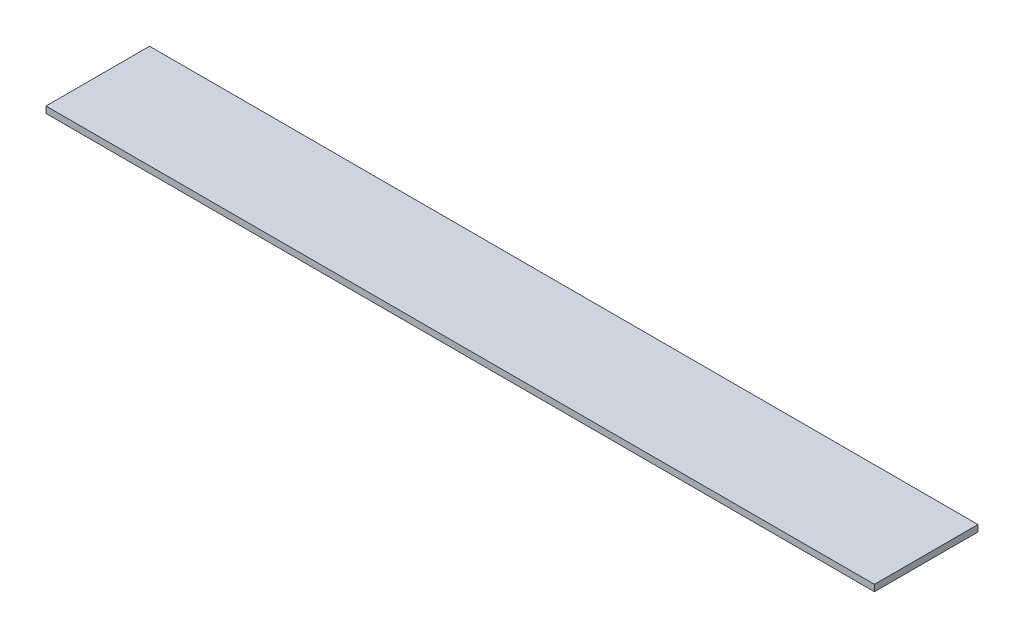
from build123d import *

# Parameters (mm, degrees)
SKETCH1_W           = 203.2
SKETCH1_H           = 25.4
BOSS_EXTRUDE1_DEPTH = 1.5875


with BuildPart() as part:
    # Sketch1 → Boss-Extrude1 (new body)
    with BuildSketch(Plane(origin=(0, 0, 0), x_dir=(1, 0, 0), z_dir=(0, 1, 0))):
        with Locations((101.6, 12.7)):
            Rectangle(SKETCH1_W, SKETCH1_H)
    extrude(amount=BOSS_EXTRUDE1_DEPTH)


solid = part.part
